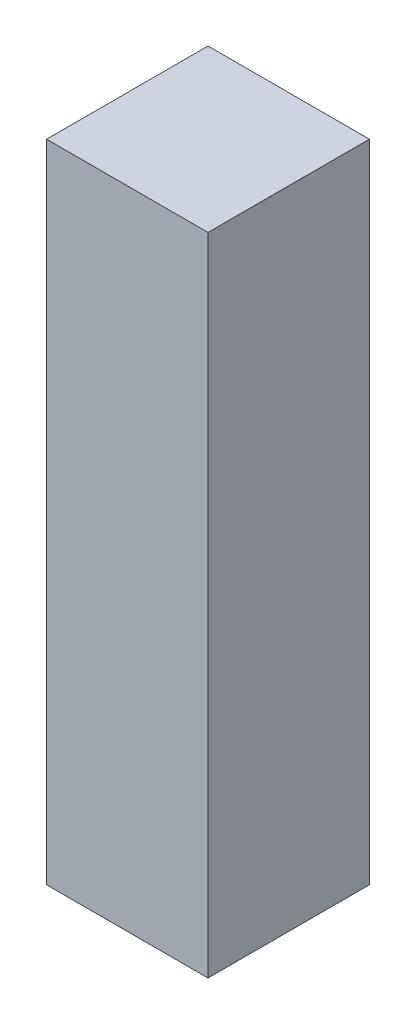
from build123d import *

# Parameters (mm, degrees)
SKETCH1_W           = 19.05
SKETCH1_H           = 19.05
BOSS_EXTRUDE1_DEPTH = 76.2


with BuildPart() as part:
    # Sketch1 → Boss-Extrude1 (new body)
    with BuildSketch(Plane(origin=(0, 0, 0), x_dir=(1, 0, 0), z_dir=(0, 1, 0))):
        Rectangle(SKETCH1_W, SKETCH1_H)
    extrude(amount=BOSS_EXTRUDE1_DEPTH)


solid = part.part
